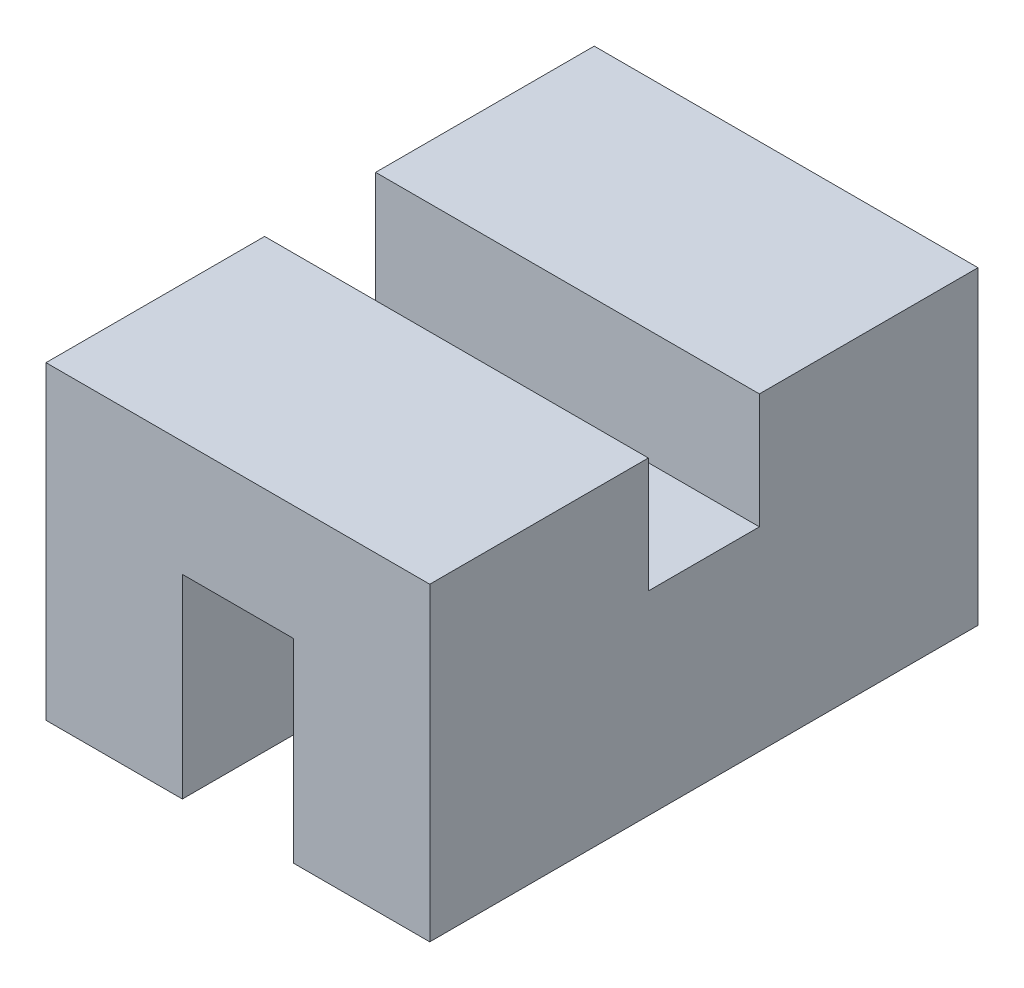
from build123d import *

# Parameters (mm, degrees)
SKETCH1_W           = 28
SKETCH1_H           = 40
BOSS_EXTRUDE1_DEPTH = 5.8
SKETCH2_W           = 28
SKETCH2_H           = 15.95
BOSS_EXTRUDE2_DEPTH = 8.4
SKETCH3_W           = 9.95
SKETCH3_H           = 40
BOSS_EXTRUDE3_DEPTH = 8.4
SKETCH4_W           = 8.1
SKETCH4_H           = 40
CUT_EXTRUDE1_DEPTH  = 5.8


with BuildPart() as part:
    # Sketch1 → Boss-Extrude1 (new body)
    with BuildSketch(Plane(origin=(0, 0, 0), x_dir=(1, 0, 0), z_dir=(0, 1, 0))):
        with Locations((14, 20)):
            Rectangle(SKETCH1_W, SKETCH1_H)
    extrude(amount=BOSS_EXTRUDE1_DEPTH)

    # Sketch2 → Boss-Extrude2 (add)
    with BuildSketch(Plane(origin=(0, 5.8, 0), x_dir=(1, 0, 0), z_dir=(0, 1, 0))):
        with Locations((14, 7.975)):
            Rectangle(SKETCH2_W, SKETCH2_H)
        with Locations((14, 32.025)):
            Rectangle(SKETCH2_W, SKETCH2_H)
    extrude(amount=BOSS_EXTRUDE2_DEPTH)

    # Sketch3 → Boss-Extrude3 (add)
    with BuildSketch(Plane.XZ):
        with Locations((4.975, -20)):
            Rectangle(SKETCH3_W, SKETCH3_H)
        with Locations((23.025, -20)):
            Rectangle(SKETCH3_W, SKETCH3_H)
    extrude(amount=BOSS_EXTRUDE3_DEPTH)

    # Sketch4 → Cut-Extrude1 (cut)
    with BuildSketch(Plane.XZ):
        with Locations((14, -20)):
            Rectangle(SKETCH4_W, SKETCH4_H)
    extrude(amount=-CUT_EXTRUDE1_DEPTH, mode=Mode.SUBTRACT)


solid = part.part
